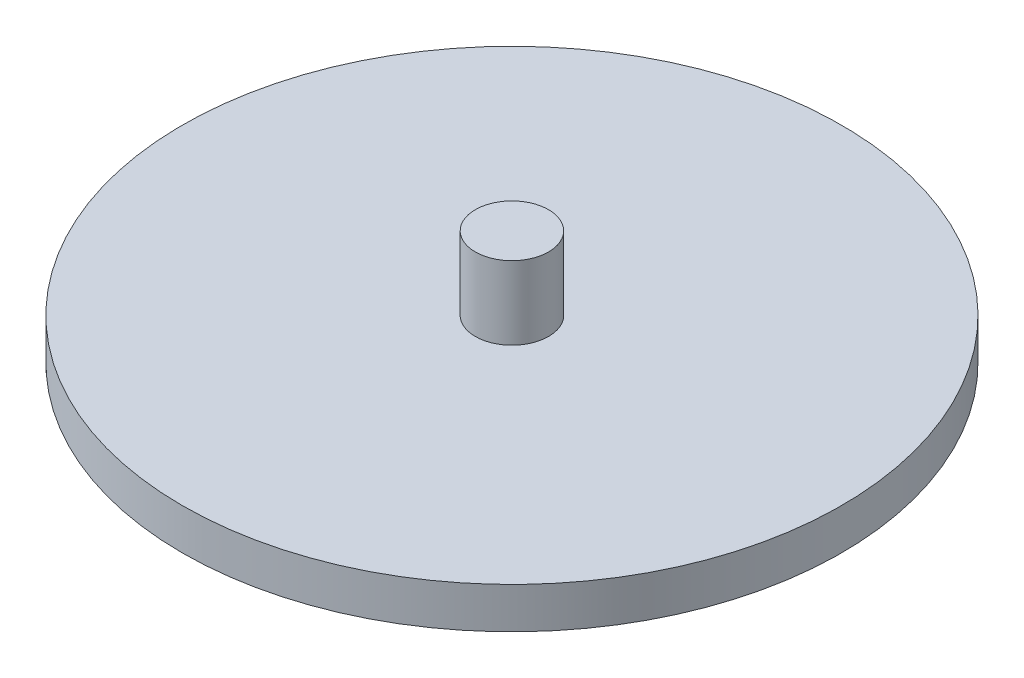
from build123d import *

# Parameters (mm, degrees)
SKETCH1_R           = 45
BOSS_EXTRUDE1_DEPTH = 2.8
SKETCH3_R           = 5
BOSS_EXTRUDE2_DEPTH = 10
BOSS_EXTRUDE3_START = -15
SKETCH3_2_R         = 5
BOSS_EXTRUDE3_DEPTH = 15


with BuildPart() as part:
    # Sketch1 → Boss-Extrude1 (new, symmetric)
    with BuildSketch(Plane(origin=(0, 0, 0), x_dir=(1, 0, 0), z_dir=(0, 1, 0))):
        Circle(SKETCH1_R)
    extrude(amount=BOSS_EXTRUDE1_DEPTH, both=True)

    # Sketch3 → Boss-Extrude2 (add)
    with BuildSketch(Plane(origin=(0, 2.8, 0), x_dir=(1, 0, 0), z_dir=(0, 1, 0))):
        Circle(SKETCH3_R)
    extrude(amount=BOSS_EXTRUDE2_DEPTH)

    # Sketch3_2 → Boss-Extrude3 (add)
    with BuildSketch(Plane(origin=(0, 2.8, 0), x_dir=(1, 0, 0), z_dir=(0, 1, 0)).offset(BOSS_EXTRUDE3_START)):
        Circle(SKETCH3_2_R)
    extrude(amount=BOSS_EXTRUDE3_DEPTH)


solid = part.part
